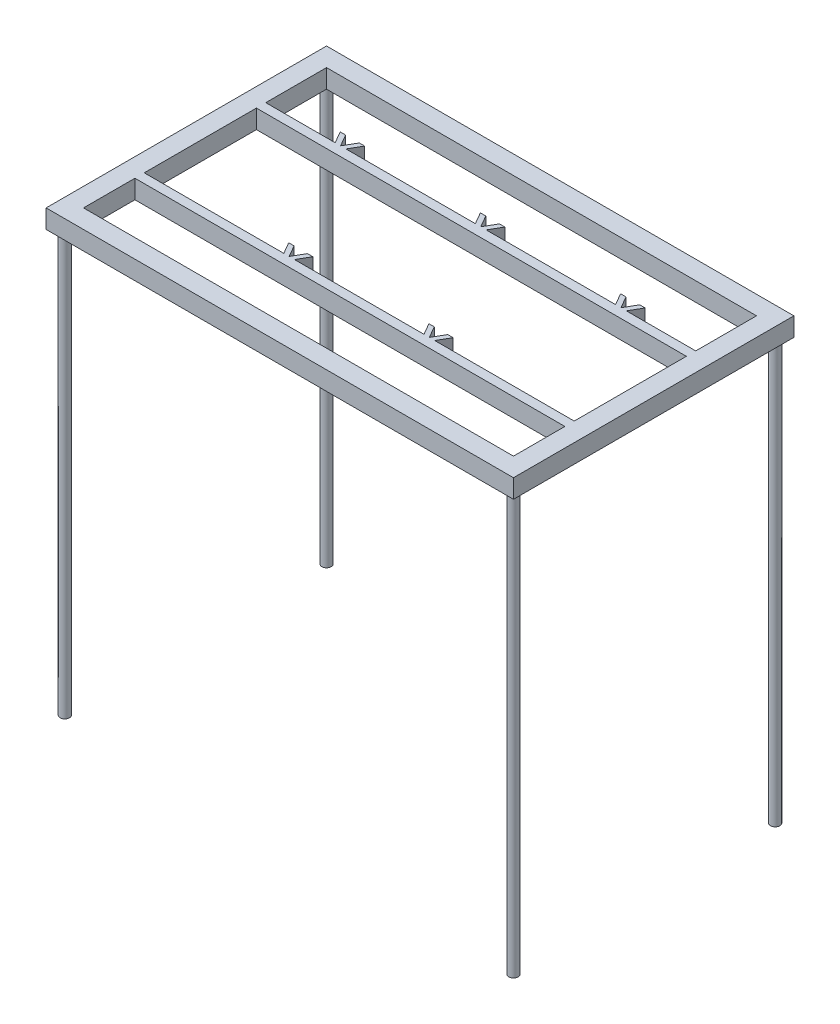
from build123d import *

# Parameters (mm, degrees)
SKETCH2_W           = 500
SKETCH2_H           = 300
BOSS_EXTRUDE1_DEPTH = 20
SKETCH5_R           = 5
BOSS_EXTRUDE2_DEPTH = 450
SKETCH7_W           = 460
SKETCH7_H           = 260
CUT_EXTRUDE1_DEPTH  = 20
SKETCH8_W           = 500
SKETCH8_H           = 10
BOSS_EXTRUDE3_DEPTH = 20
BOSS_EXTRUDE8_DEPTH = 20
BOSS_EXTRUDE9_DEPTH = 20
CUT_EXTRUDE6_DEPTH  = 20


with BuildPart() as part:
    # Sketch2 → Boss-Extrude1 (new body)
    with BuildSketch(Plane(origin=(0, 0, 0), x_dir=(1, 0, 0), z_dir=(0, 1, 0))):
        Rectangle(SKETCH2_W, SKETCH2_H)
    extrude(amount=BOSS_EXTRUDE1_DEPTH)

    # Sketch5 → Boss-Extrude2 (add)
    with BuildSketch(Plane(origin=(0, 0, 0), x_dir=(1, 0, 0), z_dir=(0, 1, 0))):
        with Locations((-240, 140)):
            Circle(SKETCH5_R)
        with Locations((240, 140)):
            Circle(SKETCH5_R)
        with Locations((-240, -140)):
            Circle(SKETCH5_R)
        with Locations((240, -140)):
            Circle(SKETCH5_R)
    extrude(amount=-BOSS_EXTRUDE2_DEPTH)

    # Sketch7 → Cut-Extrude1 (cut)
    with BuildSketch(Plane(origin=(0, 0, 0), x_dir=(-1, 0, 0), z_dir=(0, -1, 0))):
        Rectangle(SKETCH7_W, SKETCH7_H)
    extrude(amount=-CUT_EXTRUDE1_DEPTH, mode=Mode.SUBTRACT)

    # Sketch8 → Boss-Extrude3 (add)
    with BuildSketch(Plane(origin=(0, 0, 0), x_dir=(1, 0, 0), z_dir=(0, 1, 0))):
        with Locations((0, 60)):
            Rectangle(SKETCH8_W, SKETCH8_H)
        with Locations((0, -70)):
            Rectangle(SKETCH8_W, SKETCH8_H)
    extrude(amount=BOSS_EXTRUDE3_DEPTH)

    # Sketch13 → Boss-Extrude8 (add)
    with BuildSketch(Plane(origin=(0, 20, 0), x_dir=(1, 0, 0), z_dir=(0, 1, 0))):
        Polygon((75, -74.929562993), (87.929380819, -52.535218504), (62.070619181, -52.535218504), align=None)
        Polygon((-75, -74.929562993), (-62.070619181, -52.535218504), (-87.929380819, -52.535218504), align=None)
    extrude(amount=-BOSS_EXTRUDE8_DEPTH)

    # Sketch9 → Boss-Extrude9 (add)
    with BuildSketch(Plane(origin=(0, 0, 0), x_dir=(1, 0, 0), z_dir=(0, 1, 0))):
        Polygon((-150, 55), (-136.882070442, 77.720920485), (-163.117929558, 77.720920485), align=None)
        Polygon((13.117929558, 77.720920485), (-13.117929558, 77.720920485), (0, 55), align=None)
        Polygon((163.117929558, 77.720920485), (136.882070442, 77.720920485), (150, 55), align=None)
    extrude(amount=BOSS_EXTRUDE9_DEPTH)

    # Sketch14 → Cut-Extrude6 (cut)
    with BuildSketch(Plane(origin=(0, 0, 0), x_dir=(1, 0, 0), z_dir=(0, 1, 0))):
        Polygon((-150, 65), (-138.983359701, 84.081380727), (-161.016640299, 84.081380727), align=None)
        Polygon((0, 65), (11.016640299, 84.081380727), (-11.016640299, 84.081380727), align=None)
        Polygon((150, 65), (161.016640299, 84.081380727), (138.983359701, 84.081380727), align=None)
        Polygon((75, -65), (85.794817429, -46.302827755), (64.205182571, -46.302827755), align=None)
        Polygon((-75, -65), (-64.205182571, -46.302827755), (-85.794817429, -46.302827755), align=None)
    extrude(amount=CUT_EXTRUDE6_DEPTH, mode=Mode.SUBTRACT)


solid = part.part
